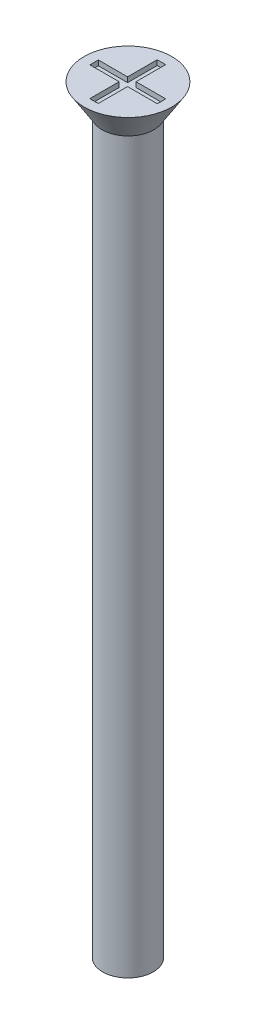
from build123d import *

# Parameters (mm, degrees)
SKETCH1_R           = 1.5
BOSS_EXTRUDE1_DEPTH = 45
SKETCH2_R           = 2.6
BOSS_EXTRUDE2_DEPTH = 1.7
BOSS_EXTRUDE2_TAPER = 32
SKETCH3_W           = 0.5
SKETCH3_H           = 1.758378485
SKETCH3_H_2         = 1.741621515
SKETCH3_W_2         = 1.734727157
SKETCH3_H_3         = 0.5
SKETCH3_W_3         = 1.765272843
CUT_EXTRUDE1_DEPTH  = 0.3


with BuildPart() as part:
    # Sketch1 → Boss-Extrude1 (new body)
    with BuildSketch(Plane(origin=(0, 0, 0), x_dir=(1, 0, 0), z_dir=(0, 1, 0))):
        Circle(SKETCH1_R)
    extrude(amount=BOSS_EXTRUDE1_DEPTH)

    # Sketch2 → Boss-Extrude2 (add)
    with BuildSketch(Plane(origin=(0, 45, 0), x_dir=(1, 0, 0), z_dir=(0, 1, 0))):
        Circle(SKETCH2_R)
    extrude(amount=-BOSS_EXTRUDE2_DEPTH, taper=BOSS_EXTRUDE2_TAPER)

    # Sketch3 → Cut-Extrude1 (cut)
    with BuildSketch(Plane(origin=(0, 45, 0), x_dir=(1, 0, 0), z_dir=(0, 1, 0))):
        with Locations((-0.015272843, 1.120810757)):
            Rectangle(SKETCH3_W, SKETCH3_H)
        with Locations((-0.015272843, -1.129189243)):
            Rectangle(SKETCH3_W, SKETCH3_H_2)
        with Locations((-1.132636421, -0.008378485)):
            Rectangle(SKETCH3_W_2, SKETCH3_H_3)
        with Locations((1.117363579, -0.008378485)):
            Rectangle(SKETCH3_W_3, SKETCH3_H_3)
        with Locations((-0.015272843, -0.008378485)):
            Rectangle(SKETCH3_W, SKETCH3_H_3)
    extrude(amount=-CUT_EXTRUDE1_DEPTH, mode=Mode.SUBTRACT)


solid = part.part
